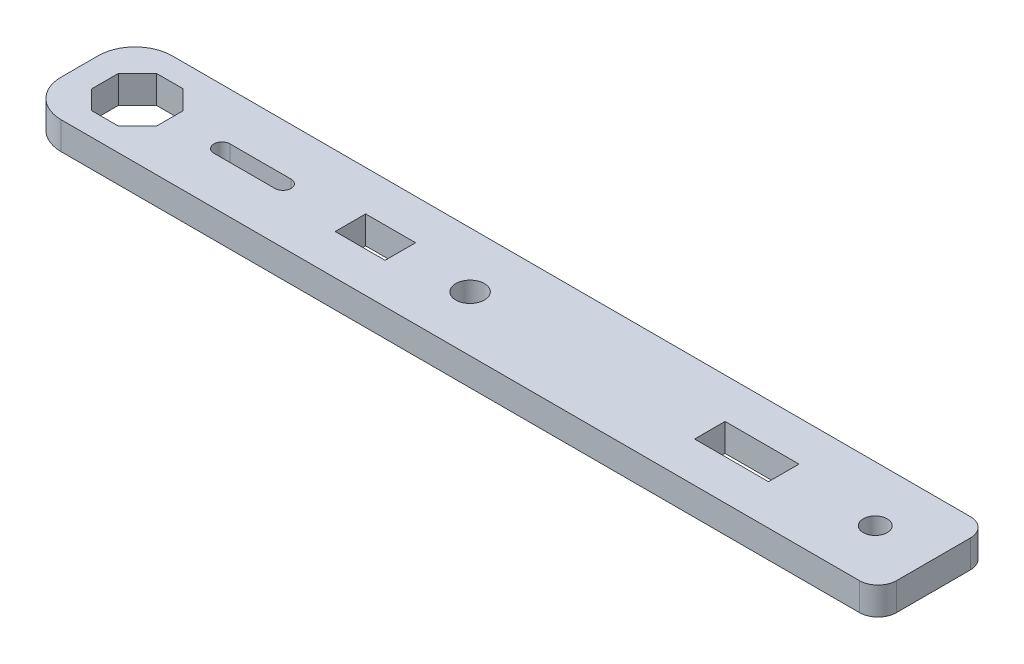
from build123d import *

# Parameters (mm, degrees)
SKETCH2_W           = 92.4
SKETCH2_H           = 12
BOSS_EXTRUDE1_DEPTH = 3
FILLET1_R           = 4
FILLET2_R           = 2
SKETCH3_R           = 1.55
SKETCH3_R_2         = 1.3
SKETCH3_W           = 5.4
SKETCH3_H           = 3
SKETCH3_W_2         = 8
CUT_EXTRUDE1_DEPTH  = 4
SKETCH4_W           = 5.4
SKETCH4_H           = 0.15
SKETCH4_W_2         = 8
CUT_EXTRUDE2_DEPTH  = 4


with BuildPart() as part:
    # Sketch2 → Boss-Extrude1 (new body)
    with BuildSketch(Plane(origin=(0, 0, 0), x_dir=(1, 0, 0), z_dir=(0, 1, 0))):
        with Locations((46.2, 6)):
            Rectangle(SKETCH2_W, SKETCH2_H)
    extrude(amount=BOSS_EXTRUDE1_DEPTH)

    # Fillet1
    fillet1_edges = [part.edges().sort_by_distance(p)[0] for p in [
        (0, 1.5, -12),
        (0, 1.5, 0),
    ]]
    fillet(fillet1_edges, radius=FILLET1_R)

    # Fillet2
    fillet2_edges = [part.edges().sort_by_distance(p)[0] for p in [
        (92.4, 1.5, -12),
        (92.4, 1.5, 0),
    ]]
    fillet(fillet2_edges, radius=FILLET2_R)

    # Sketch3 → Cut-Extrude1 (cut, through all)
    with BuildSketch(Plane(origin=(0, 3, 0), x_dir=(1, 0, 0), z_dir=(0, 1, 0))):
        with Locations((42.25, 6)):
            Circle(SKETCH3_R)
        with Locations((86.1, 6)):
            Circle(SKETCH3_R_2)
        Polygon((9.75, 7.449747468), (7.699747468, 9.5), (4.800252532, 9.5), (2.75, 7.449747468), (2.75, 4.550252532), (4.800252532, 2.5), (7.699747468, 2.5), (9.75, 4.550252532), align=None)
        with BuildLine():
            Line((15.4, 6.875), (22, 6.875))
            ThreePointArc((22, 6.875), (22.875, 6), (22, 5.125))
            Line((22, 5.125), (15.4, 5.125))
            ThreePointArc((15.4, 5.125), (14.525, 6), (15.4, 6.875))
        make_face()
        with Locations((32, 6)):
            Rectangle(SKETCH3_W, SKETCH3_H)
        with Locations((72.2, 6)):
            Rectangle(SKETCH3_W_2, SKETCH3_H)
    extrude(amount=-CUT_EXTRUDE1_DEPTH, mode=Mode.SUBTRACT)

    # Sketch4 → Cut-Extrude2 (cut, through all)
    with BuildSketch(Plane(origin=(0, 3, 0), x_dir=(1, 0, 0), z_dir=(0, 1, 0))):
        with Locations((32, 7.575)):
            Rectangle(SKETCH4_W, SKETCH4_H)
        with Locations((32, 4.425)):
            Rectangle(SKETCH4_W, SKETCH4_H)
        with Locations((72.2, 7.575)):
            Rectangle(SKETCH4_W_2, SKETCH4_H)
        with Locations((72.2, 4.425)):
            Rectangle(SKETCH4_W_2, SKETCH4_H)
    extrude(amount=-CUT_EXTRUDE2_DEPTH, mode=Mode.SUBTRACT)


solid = part.part
